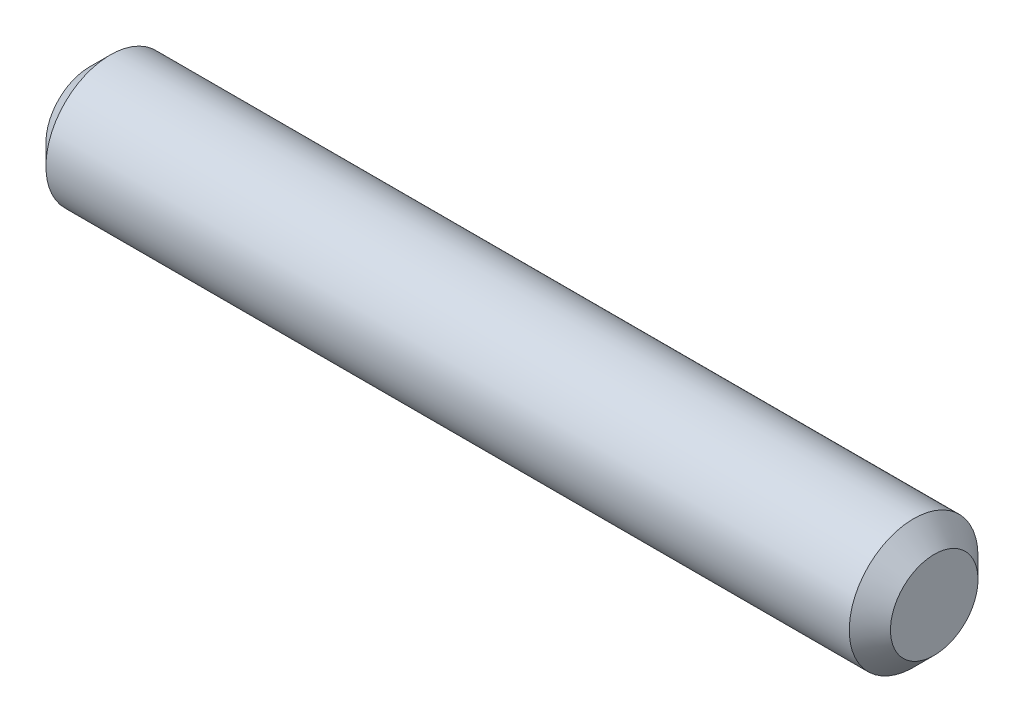
from build123d import *

# Parameters (mm, degrees)
SKETCH1_R           = 1.5875
BOSS_EXTRUDE1_DEPTH = 10.414
CHAMFER1_SIZE       = 0.508


with BuildPart() as part:
    # Sketch1 → Boss-Extrude1 (new, symmetric)
    with BuildSketch(Plane(origin=(0, 0, 0), x_dir=(0, 0, -1), z_dir=(1, 0, 0))):
        Circle(SKETCH1_R)
    extrude(amount=BOSS_EXTRUDE1_DEPTH, both=True)

    # Chamfer1
    chamfer1_edges = [part.edges().sort_by_distance(p)[0] for p in [
        (-10.414, 0, 1.5875),
        (10.414, 0, 1.5875),
    ]]
    chamfer(chamfer1_edges, length=CHAMFER1_SIZE)


solid = part.part
